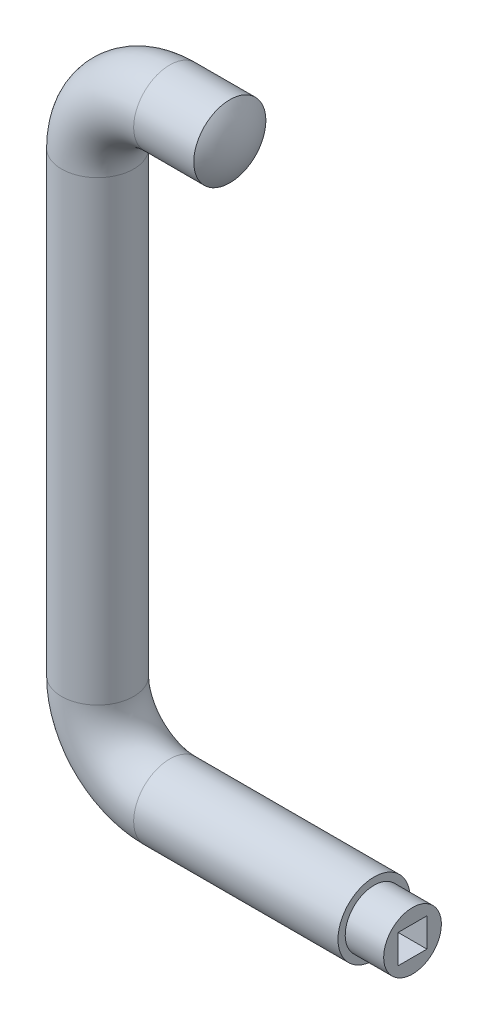
from build123d import *

# Parameters (mm, degrees)
SWEEP_THIN1_PROFILE_R   = 7.5
SWEEP_THIN1_PROFILE_R_2 = 6
SKETCH29_R              = 7.5
BOSS_EXTRUDE1_DEPTH     = 8
SKETCH30_R              = 6
BOSS_EXTRUDE2_DEPTH     = 8
SKETCH31_W              = 6
SKETCH31_H              = 6
CUT_EXTRUDE2_DEPTH      = 16


with BuildPart() as part:
    # Sweep-Thin1: sweep along a path in Sketch2
    with BuildLine(Plane.XY) as sweep_thin1_path:
        Line((0, 0), (-34.5, 0))
        ThreePointArc((-34.5, 0), (-45.106601718, 4.393398282), (-49.5, 15))
        Line((-49.5, 15), (-49.5, 110))
        ThreePointArc((-49.5, 110), (-45.106601718, 120.606601718), (-34.5, 125))
        Line((-34.5, 125), (-22, 125))
    # Sweep-Thin1 profile (on start of the path) → Sweep-Thin1 (sweep)
    with BuildSketch(Plane(origin=(0, 0, 0), x_dir=(0, -1, 0), z_dir=(-1, 0, 0))):
        Circle(SWEEP_THIN1_PROFILE_R)
        Circle(SWEEP_THIN1_PROFILE_R_2, mode=Mode.SUBTRACT)
    sweep(path=sweep_thin1_path.line)

    # Sketch27 → Revolve1 (revolve)
    with BuildSketch(Plane.XY):
        with BuildLine():
            Line((-22, 132.5), (-22, 125))
            Line((-22, 125), (-19.5, 125))
            ThreePointArc((-19.5, 125), (-20.141458774, 128.952847075), (-22, 132.5))
        make_face()
    revolve(axis=Axis((-22, 125, 0), (1, 0, 0)))

    # Sketch29 → Boss-Extrude1 (add)
    with BuildSketch(Plane(origin=(0, 0, 0), x_dir=(0, 0, -1), z_dir=(1, 0, 0))):
        Circle(SKETCH29_R)
    extrude(amount=BOSS_EXTRUDE1_DEPTH)

    # Sketch30 → Boss-Extrude2 (add)
    with BuildSketch(Plane(origin=(8, 0, 0), x_dir=(0, 0, -1), z_dir=(1, 0, 0))):
        Circle(SKETCH30_R)
    extrude(amount=BOSS_EXTRUDE2_DEPTH)

    # Sketch31 → Cut-Extrude2 (cut)
    with BuildSketch(Plane(origin=(16, 0, 0), x_dir=(0, 0, -1), z_dir=(1, 0, 0))):
        Rectangle(SKETCH31_W, SKETCH31_H)
    extrude(amount=-CUT_EXTRUDE2_DEPTH, mode=Mode.SUBTRACT)


solid = part.part
